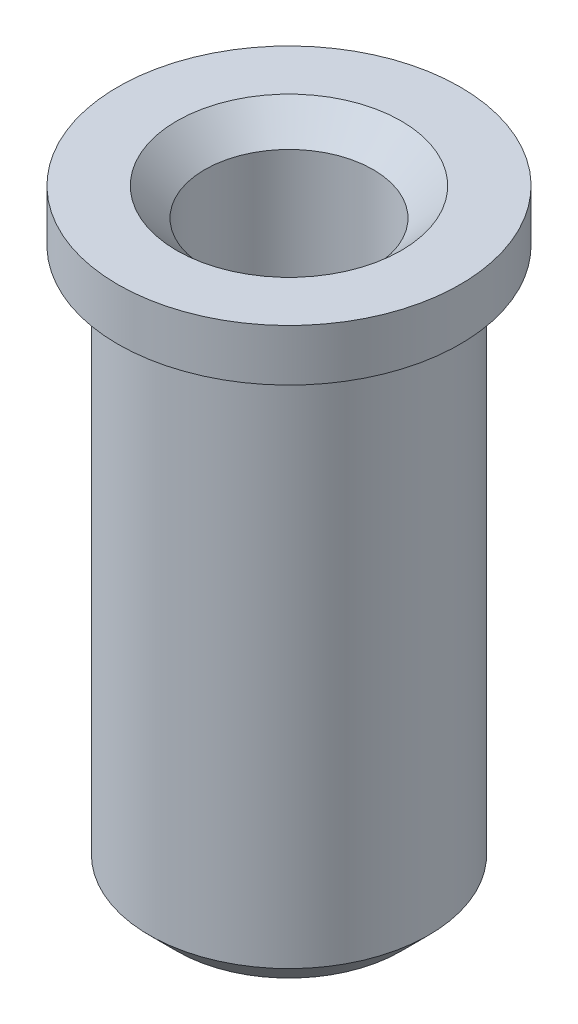
from build123d import *

# Parameters (mm, degrees)
F_1_5_1_5_DIAMETER_HOLE1_D     = 1.5
F_1_5_1_5_DIAMETER_HOLE1_DEPTH = 4.57
F_1_5_1_5_DIAMETER_HOLE1_TIP   = 0.450645464
CHAMFER1_SIZE                  = 0.25
CHAMFER2_SIZE                  = 0.25


with BuildPart() as part:
    # Sketch1 → Revolve1 (revolve)
    with BuildSketch(Plane(origin=(0, 0, 0), x_dir=(0, 0, -1), z_dir=(1, 0, 0))):
        Polygon((0, 2.705), (1.525, 2.705), (1.525, 2.245), (1.245, 2.245), (1.245, -2.705), (0, -2.705), align=None)
    revolve(axis=Axis((0, 0, 0), (0, 1, 0)))

    # Ø1.5 (1.5) Diameter Hole1
    with Locations(Plane.ZX.offset(2.705)):
        with Locations((0, 0)):
            Hole(F_1_5_1_5_DIAMETER_HOLE1_D / 2, depth=F_1_5_1_5_DIAMETER_HOLE1_DEPTH)
            with Locations((0, 0, -(F_1_5_1_5_DIAMETER_HOLE1_DEPTH + F_1_5_1_5_DIAMETER_HOLE1_TIP / 2))):  # 118° drill point
                Cone(0, F_1_5_1_5_DIAMETER_HOLE1_D / 2, F_1_5_1_5_DIAMETER_HOLE1_TIP, mode=Mode.SUBTRACT)

    # Chamfer1
    chamfer1_edges = [part.edges().sort_by_distance(p)[0] for p in [
        (0, -2.705, 1.245),
    ]]
    chamfer(chamfer1_edges, length=CHAMFER1_SIZE)

    # Chamfer2
    chamfer2_edges = [part.edges().sort_by_distance(p)[0] for p in [
        (0, 2.705, 0.75),
    ]]
    chamfer(chamfer2_edges, length=CHAMFER2_SIZE)


solid = part.part
